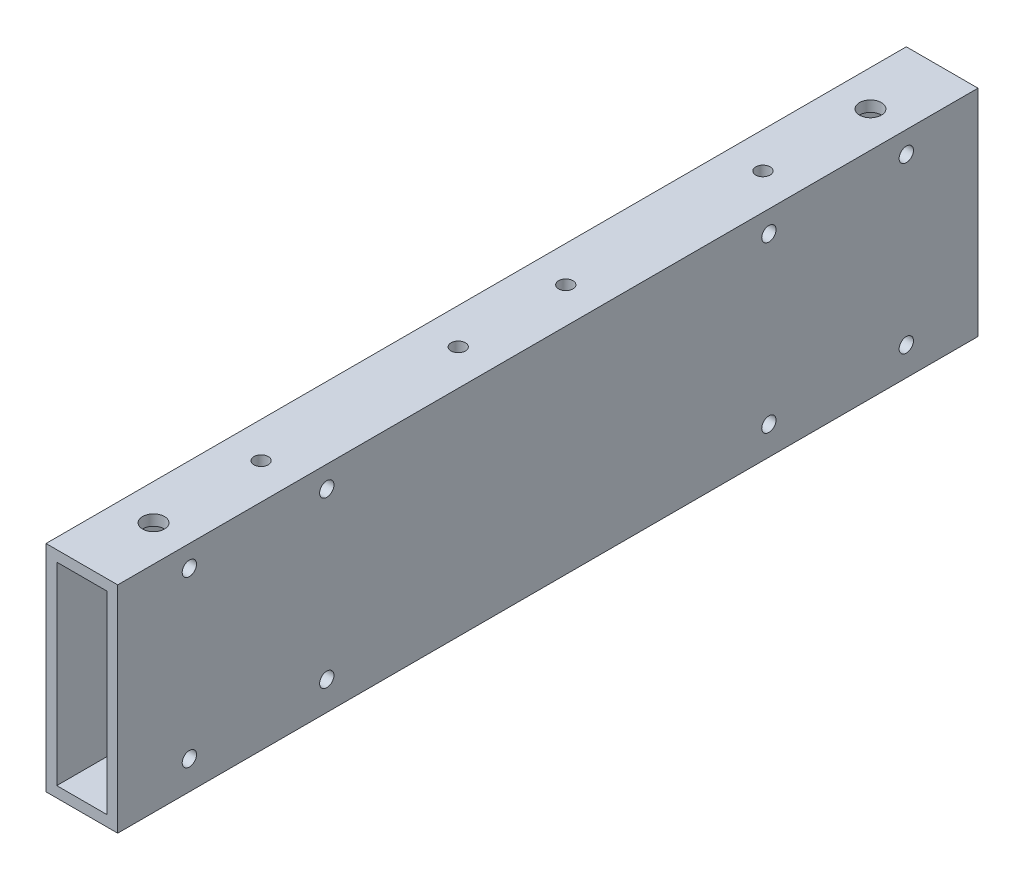
from build123d import *

# Parameters (mm, degrees)
SKETCH_1_W          = 20
SKETCH_1_H          = 60
EXTRUDE_1_DEPTH     = 240
SKETCH_2_W          = 14
SKETCH_2_H          = 54
CUT_EXTRUDE_1_DEPTH = 241
SKETCH_3_R          = 2
CUT_EXTRUDE_2_DEPTH = 240
SKETCH_4_R          = 3.05
SKETCH_4_R_2        = 2
CUT_EXTRUDE_3_DEPTH = 61


with BuildPart() as part:
    # 草图1 → 凸台-拉伸1 (new body)
    with BuildSketch(Plane.XY):
        with Locations((-26.616848502, -4.212119477)):
            Rectangle(SKETCH_1_W, SKETCH_1_H)
    extrude(amount=EXTRUDE_1_DEPTH)

    # 草图2 → 切除-拉伸1 (cut, through all)
    with BuildSketch(Plane.XY.offset(240)):
        with Locations((-26.616848502, -4.212119477)):
            Rectangle(SKETCH_2_W, SKETCH_2_H)
    extrude(amount=-CUT_EXTRUDE_1_DEPTH, mode=Mode.SUBTRACT)

    # 草图3 → 切除-拉伸2 (cut)
    with BuildSketch(Plane(origin=(-16.616848502, 0, 0), x_dir=(0, 0, -1), z_dir=(1, 0, 0))):
        with Locations((-220, 19.787880523)):
            Circle(SKETCH_3_R)
        with Locations((-20, 19.787880523)):
            Circle(SKETCH_3_R)
        with Locations((-181.67, 19.787880523)):
            Circle(SKETCH_3_R)
        with Locations((-220, -26.212119477)):
            Circle(SKETCH_3_R)
        with Locations((-181.67, -26.212119477)):
            Circle(SKETCH_3_R)
        with Locations((-20, -26.212119477)):
            Circle(SKETCH_3_R)
        with Locations((-58.33, -26.212119477)):
            Circle(SKETCH_3_R)
        with Locations((-58.33, 19.787880523)):
            Circle(SKETCH_3_R)
    extrude(amount=-CUT_EXTRUDE_2_DEPTH, mode=Mode.SUBTRACT)

    # 草图4 → 切除-拉伸3 (cut, through all)
    with BuildSketch(Plane(origin=(0, 25.787880523, 0), x_dir=(1, 0, 0), z_dir=(0, 1, 0))):
        with Locations((-26.616848502, -220)):
            Circle(SKETCH_4_R)
        with Locations((-26.616848502, -190)):
            Circle(SKETCH_4_R_2)
        with Locations((-26.616848502, -135)):
            Circle(SKETCH_4_R_2)
        with Locations((-26.616848502, -50)):
            Circle(SKETCH_4_R_2)
        with Locations((-26.616848502, -20)):
            Circle(SKETCH_4_R)
        with Locations((-26.616848502, -105)):
            Circle(SKETCH_4_R_2)
    extrude(amount=-CUT_EXTRUDE_3_DEPTH, mode=Mode.SUBTRACT)


solid = part.part
